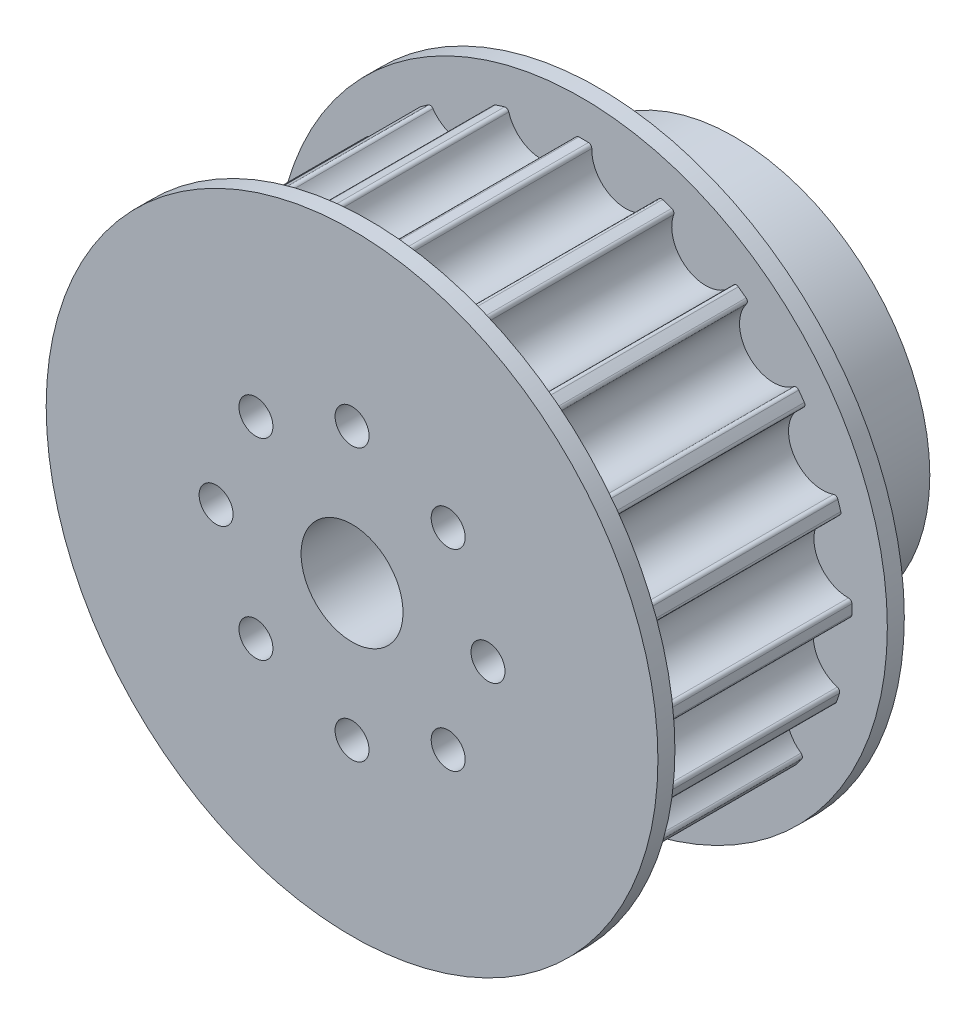
from build123d import *

# Parameters (mm, degrees)
ESQUISSE1_R                  = 11.5
BOSS_EXTRU_1_DEPTH           = 8
ESQUISSE2_R                  = 18
BOSS_EXTRU_2_DEPTH           = 1
BOSS_EXTRU_3_DEPTH           = 12.5
R_P_TITION_CIRCULAIRE1_COUNT = 20
CONG_1_R                     = 0.2
ESQUISSE7_R                  = 12.915
BOSS_EXTRU_5_DEPTH           = 12.5
ESQUISSE8_R                  = 18
BOSS_EXTRU_6_DEPTH           = 1
ESQUISSE9_R                  = 3
ENL_V_MAT_EXTRU_1_DEPTH      = 23.5
ESQUISSE10_R                 = 1
ENL_V_MAT_EXTRU_2_DEPTH      = 23.5
R_P_TITION_CIRCULAIRE2_COUNT = 8


with BuildPart() as part:
    # Esquisse1 → Boss.-Extru.1 (new body)
    with BuildSketch(Plane.XY):
        Circle(ESQUISSE1_R)
    extrude(amount=BOSS_EXTRU_1_DEPTH)

    # Esquisse2 → Boss.-Extru.2 (add)
    with BuildSketch(Plane.XY.offset(8)):
        Circle(ESQUISSE2_R)
    extrude(amount=BOSS_EXTRU_2_DEPTH)

    # Esquisse3 → Boss.-Extru.3 (add)
    with BuildSketch(Plane.XY.offset(9)):
        with BuildLine():
            Line((0.134412443, 15.91443239), (0.109075507, 12.914539385))
            ThreePointArc((0.109075507, 12.914539385), (-1.916885488, 12.771952671), (-3.895442438, 12.313519124))
            Line((-3.895442438, 12.313519124), (-4.800307116, 15.173802312))
            ThreePointArc((-4.800307116, 15.173802312), (-4.561357896, 15.247335477), (-4.321283067, 15.317106047))
            ThreePointArc((-4.321283067, 15.317106047), (-2.056408964, 13.701540321), (-0.365587557, 15.910800443))
            ThreePointArc((-0.365587557, 15.910800443), (-0.115601822, 15.914580146), (0.134412443, 15.91443239))
        make_face()
    boss_extru_3 = extrude(amount=BOSS_EXTRU_3_DEPTH)

    # Répétition circulaire1: Boss.-Extru.3 ×20 about axis
    r_p_tition_circulaire1_axis = Axis((0, 0, 0), (0, 0, 1))
    for i in range(1, R_P_TITION_CIRCULAIRE1_COUNT):
        add(boss_extru_3.rotate(r_p_tition_circulaire1_axis, i * 360 / R_P_TITION_CIRCULAIRE1_COUNT))

    # Congé1
    cong_1_edges = [part.edges().sort_by_distance(p)[0] for p in [
        (0.623461654, 15.902783422, 15.25),
        (-8.843030493, 13.232083612, 15.25),
        (-5.26440216, 15.019097673, 15.25),
        (-12.499160481, 9.851812639, 15.25),
        (-9.647900399, 12.657220978, 15.25),
        (-14.931785554, 5.507177604, 15.25),
        (-13.086994927, 9.056367306, 15.25),
        (-15.902783422, 0.623461654, 15.25),
        (-15.245043209, 4.569013302, 15.25),
        (-15.317106047, -4.321283067, 15.25),
        (-15.910800443, -0.365587557, 15.25),
        (-13.232083612, -8.843030493, 15.25),
        (-15.019097673, -5.26440216, 15.25),
        (-9.851812639, -12.499160481, 15.25),
        (-12.657220978, -9.647900399, 15.25),
        (-5.507177604, -14.931785554, 15.25),
        (-9.056367306, -13.086994927, 15.25),
        (-0.623461654, -15.902783422, 15.25),
        (-4.569013302, -15.245043209, 15.25),
        (4.321283067, -15.317106047, 15.25),
        (0.365587557, -15.910800443, 15.25),
        (8.843030493, -13.232083612, 15.25),
        (5.26440216, -15.019097673, 15.25),
        (12.499160481, -9.851812639, 15.25),
        (9.647900399, -12.657220978, 15.25),
        (14.931785554, -5.507177604, 15.25),
        (13.086994927, -9.056367306, 15.25),
        (15.902783422, -0.623461654, 15.25),
        (15.245043209, -4.569013302, 15.25),
        (15.317106047, 4.321283067, 15.25),
        (15.910800443, 0.365587557, 15.25),
        (13.232083612, 8.843030493, 15.25),
        (15.019097673, 5.26440216, 15.25),
        (9.851812639, 12.499160481, 15.25),
        (12.657220978, 9.647900399, 15.25),
        (5.507177604, 14.931785554, 15.25),
        (9.056367306, 13.086994927, 15.25),
        (4.569013302, 15.245043209, 15.25),
        (-4.321283067, 15.317106047, 15.25),
        (-0.365587557, 15.910800443, 15.25),
    ]]
    fillet(cong_1_edges, radius=CONG_1_R)

    # Esquisse7 → Boss.-Extru.5 (add)
    with BuildSketch(Plane.XY.offset(9)):
        Circle(ESQUISSE7_R)
    extrude(amount=BOSS_EXTRU_5_DEPTH)

    # Esquisse8 → Boss.-Extru.6 (add)
    with BuildSketch(Plane.XY.offset(21.5)):
        Circle(ESQUISSE8_R)
    extrude(amount=BOSS_EXTRU_6_DEPTH)

    # Esquisse9 → Enlèv. mat.-Extru.1 (cut, through all)
    with BuildSketch(Plane.XY.offset(22.5)):
        Circle(ESQUISSE9_R)
    extrude(amount=-ENL_V_MAT_EXTRU_1_DEPTH, mode=Mode.SUBTRACT)

    # Esquisse10 → Enlèv. mat.-Extru.2 (cut, through all)
    with BuildSketch(Plane(origin=(0, 0, 0), x_dir=(-1, 0, 0), z_dir=(0, 0, -1))):
        with Locations((0, 8)):
            Circle(ESQUISSE10_R)
    enl_v_mat_extru_2 = extrude(amount=-ENL_V_MAT_EXTRU_2_DEPTH, mode=Mode.SUBTRACT)

    # Répétition circulaire2: Enlèv. mat.-Extru.2 ×8 about axis
    r_p_tition_circulaire2_axis = Axis((0, 0, 0), (0, 0, 1))
    for i in range(1, R_P_TITION_CIRCULAIRE2_COUNT):
        add(enl_v_mat_extru_2.rotate(r_p_tition_circulaire2_axis, i * 360 / R_P_TITION_CIRCULAIRE2_COUNT), mode=Mode.SUBTRACT)


solid = part.part
